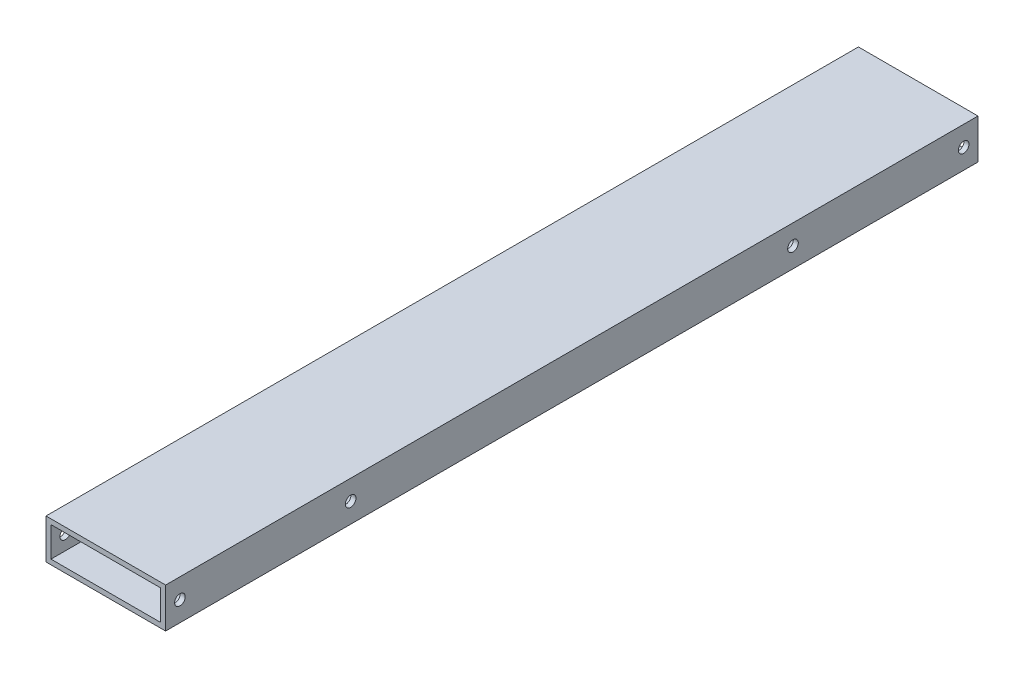
from build123d import *

# Parameters (mm, degrees)
SKETCH1_W           = 76.2
SKETCH1_H           = 25.4
SKETCH1_W_2         = 69.85
SKETCH1_H_2         = 19.05
BOSS_EXTRUDE1_DEPTH = 517.525
SKETCH3_R           = 3.3782
CUT_EXTRUDE1_DEPTH  = 77.2


with BuildPart() as part:
    # Sketch1 → Boss-Extrude1 (new body)
    with BuildSketch(Plane.XY):
        with Locations((38.1, 12.7)):
            Rectangle(SKETCH1_W, SKETCH1_H)
        with Locations((38.1, 12.7)):
            Rectangle(SKETCH1_W_2, SKETCH1_H_2, mode=Mode.SUBTRACT)
    extrude(amount=BOSS_EXTRUDE1_DEPTH)

    # Sketch3 → Cut-Extrude1 (cut, through all)
    with BuildSketch(Plane(origin=(76.2, 0, 0), x_dir=(0, 0, -1), z_dir=(1, 0, 0))):
        with Locations((-508.3937, 12.7)):
            Circle(SKETCH3_R)
        with Locations((-399.6563, 12.7)):
            Circle(SKETCH3_R)
    cut_extrude1 = extrude(amount=-CUT_EXTRUDE1_DEPTH, mode=Mode.SUBTRACT)

    # Mirror1: Cut-Extrude1 across plane
    add(cut_extrude1.mirror(Plane(origin=(0, 0, 258.7625), x_dir=(1, 0, 0), z_dir=(0, 0, -1))), mode=Mode.SUBTRACT)


solid = part.part
